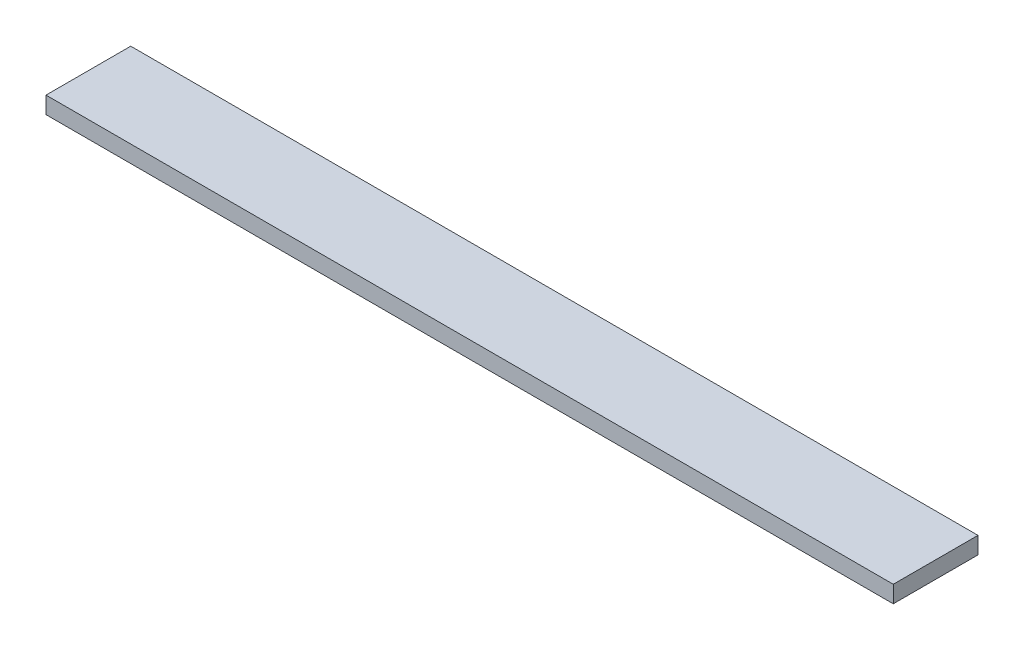
from build123d import *

# Parameters (mm, degrees)
SKETCH_1_W      = 20
SKETCH_1_H      = 4
EXTRUDE_1_DEPTH = 200


with BuildPart() as part:
    # Эскиз1 → Бобышка-Вытянуть1 (new body)
    with BuildSketch(Plane(origin=(0, 0, 0), x_dir=(0, 0, -1), z_dir=(1, 0, 0))):
        with Locations((10, 2)):
            Rectangle(SKETCH_1_W, SKETCH_1_H)
    extrude(amount=EXTRUDE_1_DEPTH)


solid = part.part
